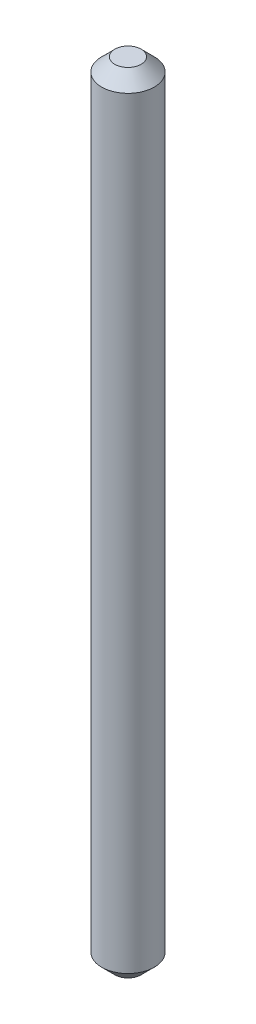
from build123d import *

# Parameters (mm, degrees)
SZKIC1_R                    = 1
DODANIE_WYCI_GNI_CIE1_DEPTH = 15
SFAZOWANIE1_SIZE            = 0.5


with BuildPart() as part:
    # Szkic1 → Dodanie-wyciągnięcie1 (new body, symmetric)
    with BuildSketch(Plane(origin=(0, 0, 0), x_dir=(1, 0, 0), z_dir=(0, 1, 0))):
        Circle(SZKIC1_R)
    extrude(amount=DODANIE_WYCI_GNI_CIE1_DEPTH, both=True)

    # Sfazowanie1
    sfazowanie1_edges = [part.edges().sort_by_distance(p)[0] for p in [
        (-1, -15, 0),
        (-1, 15, 0),
    ]]
    chamfer(sfazowanie1_edges, length=SFAZOWANIE1_SIZE)


solid = part.part
